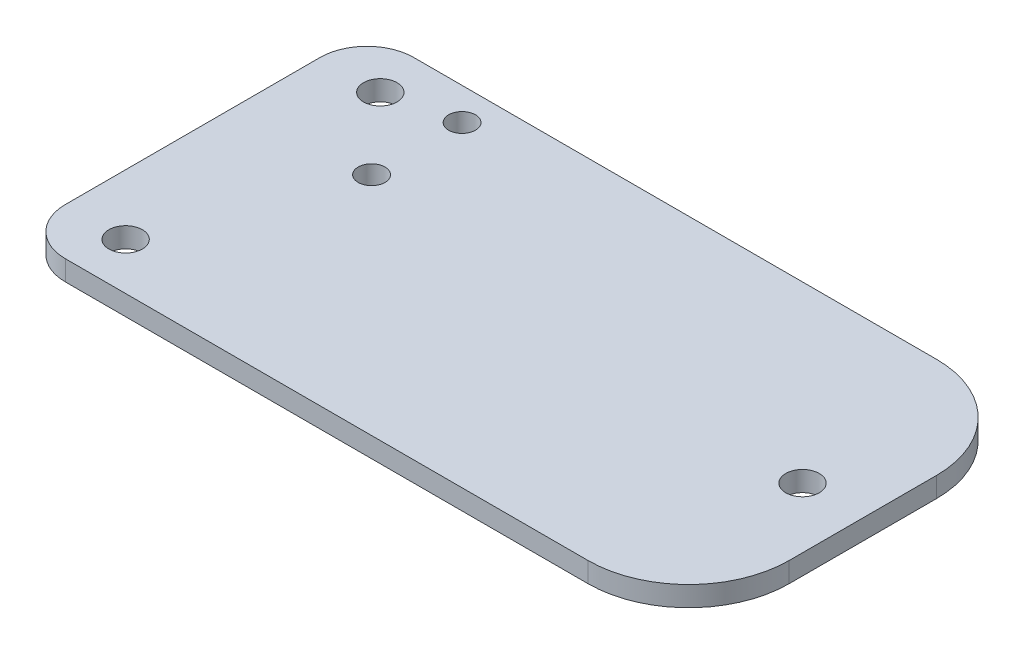
from build123d import *

# Parameters (mm, degrees)
SKETCH1_W           = 100
SKETCH1_H           = 52
SKETCH1_R           = 2.5
SKETCH1_R_2         = 2
BOSS_EXTRUDE1_DEPTH = 3
FILLET1_R           = 15
FILLET2_R           = 7


with BuildPart() as part:
    # Sketch1 → Boss-Extrude1 (new body)
    with BuildSketch(Plane(origin=(0, 0, 0), x_dir=(1, 0, 0), z_dir=(0, 1, 0))):
        Rectangle(SKETCH1_W, SKETCH1_H)
        with Locations((41, 0)):
            Circle(SKETCH1_R, mode=Mode.SUBTRACT)
        with Locations((-41, 19)):
            Circle(SKETCH1_R, mode=Mode.SUBTRACT)
        with Locations((-41, -19)):
            Circle(SKETCH1_R, mode=Mode.SUBTRACT)
        with Locations((-31, 21.2)):
            Circle(SKETCH1_R_2, mode=Mode.SUBTRACT)
        with Locations((-31, 7.7)):
            Circle(SKETCH1_R_2, mode=Mode.SUBTRACT)
    extrude(amount=BOSS_EXTRUDE1_DEPTH)

    # Fillet1
    fillet1_edges = [part.edges().sort_by_distance(p)[0] for p in [
        (50, 1.5, 26),
        (50, 1.5, -26),
    ]]
    fillet(fillet1_edges, radius=FILLET1_R)

    # Fillet2
    fillet2_edges = [part.edges().sort_by_distance(p)[0] for p in [
        (-50, 1.5, 26),
        (-50, 1.5, -26),
    ]]
    fillet(fillet2_edges, radius=FILLET2_R)


solid = part.part
